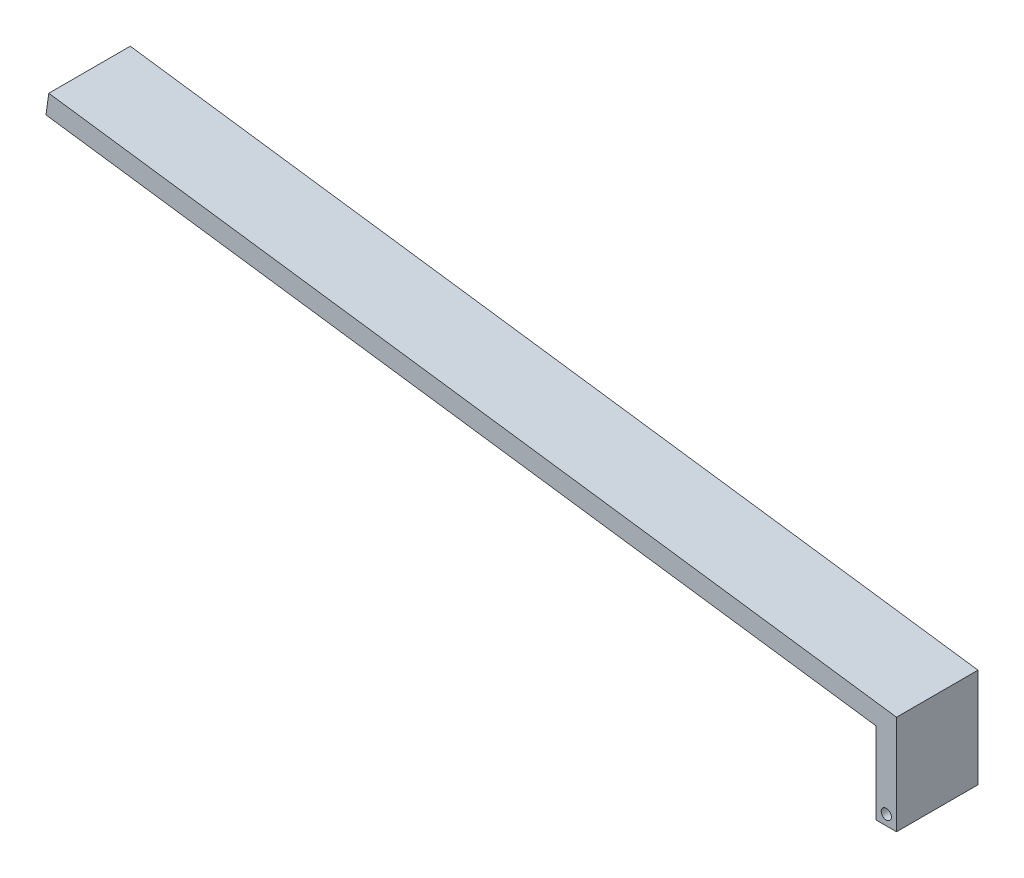
from build123d import *

# Parameters (mm, degrees)
EXTRUDE1_DEPTH = 4
SKETCH2_R      = 0.25
EXTRUDE2_DEPTH = 14


with BuildPart() as part:
    # Sketch1 → Extrude1 (new body)
    with BuildSketch(Plane.XY):
        Polygon((17.10439198, -5.320799179), (18.10439198, -5.320799179), (18.10439198, -0.44883862), (-23.504455273, 5.269887661), (-23.640615422, 4.279200821), (17.10439198, -1.320799179), align=None)
    extrude(amount=EXTRUDE1_DEPTH)

    # Sketch2 → Extrude2 (cut)
    with BuildSketch(Plane.XY.offset(4)):
        with Locations((17.60439198, -4.820799179)):
            Circle(SKETCH2_R)
    extrude(amount=-EXTRUDE2_DEPTH, mode=Mode.SUBTRACT)


solid = part.part
